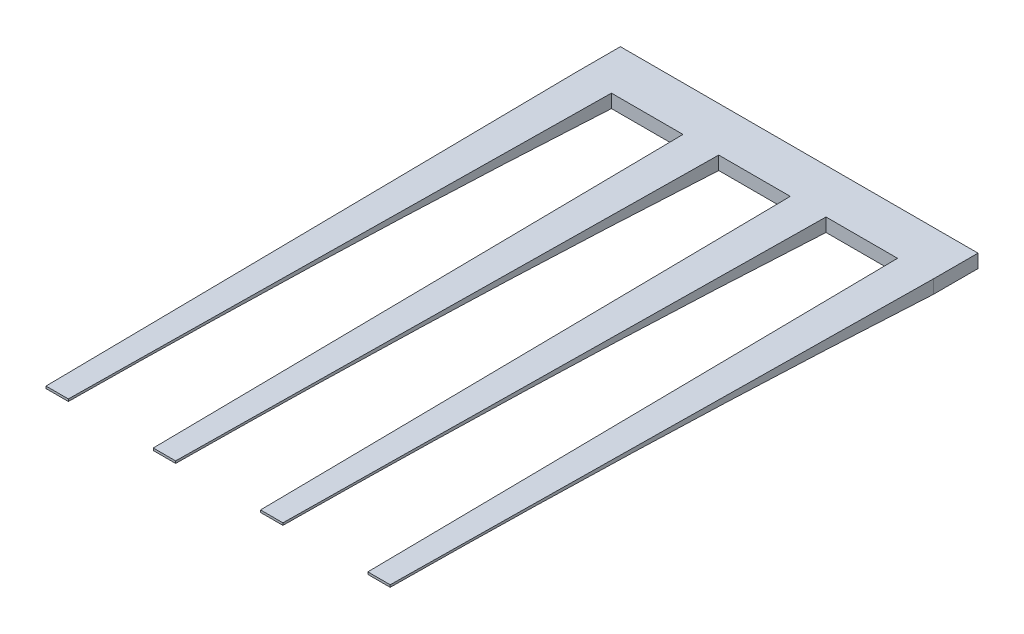
from build123d import *

# Parameters (mm, degrees)
SKETCH1_W           = 1600
SKETCH1_H           = 60
BOSS_EXTRUDE1_DEPTH = 200
SKETCH2_W           = 160
SKETCH2_H           = 60
SKETCH3_W           = 130
SKETCH3_H           = 20
SKETCH4_W           = 100
SKETCH4_H           = 10
LPATTERN1_COUNT     = 4
LPATTERN1_PITCH     = 480


with BuildPart() as part:
    # Sketch1 → Boss-Extrude1 (new body)
    with BuildSketch(Plane.XY):
        with Locations((800, -30)):
            Rectangle(SKETCH1_W, SKETCH1_H)
    extrude(amount=BOSS_EXTRUDE1_DEPTH)

    # Sketch2 → Loft1 section 0
    with BuildSketch(Plane.XY.offset(200)):
        with Locations((80, -30)):
            Rectangle(SKETCH2_W, SKETCH2_H)
    # Sketch3 → Loft1 section 1
    with BuildSketch(Plane.XY.offset(1400)):
        with Locations((80, -10)):
            Rectangle(SKETCH3_W, SKETCH3_H)
    # Sketch4 → Loft1 section 2
    with BuildSketch(Plane.XY.offset(2600)):
        with Locations((80, -5)):
            Rectangle(SKETCH4_W, SKETCH4_H)
    loft1 = loft()

    # LPattern1: Loft1 ×4
    with Locations(*[(i * LPATTERN1_PITCH, 0, 0) for i in range(1, LPATTERN1_COUNT)]):
        add(loft1)


solid = part.part
